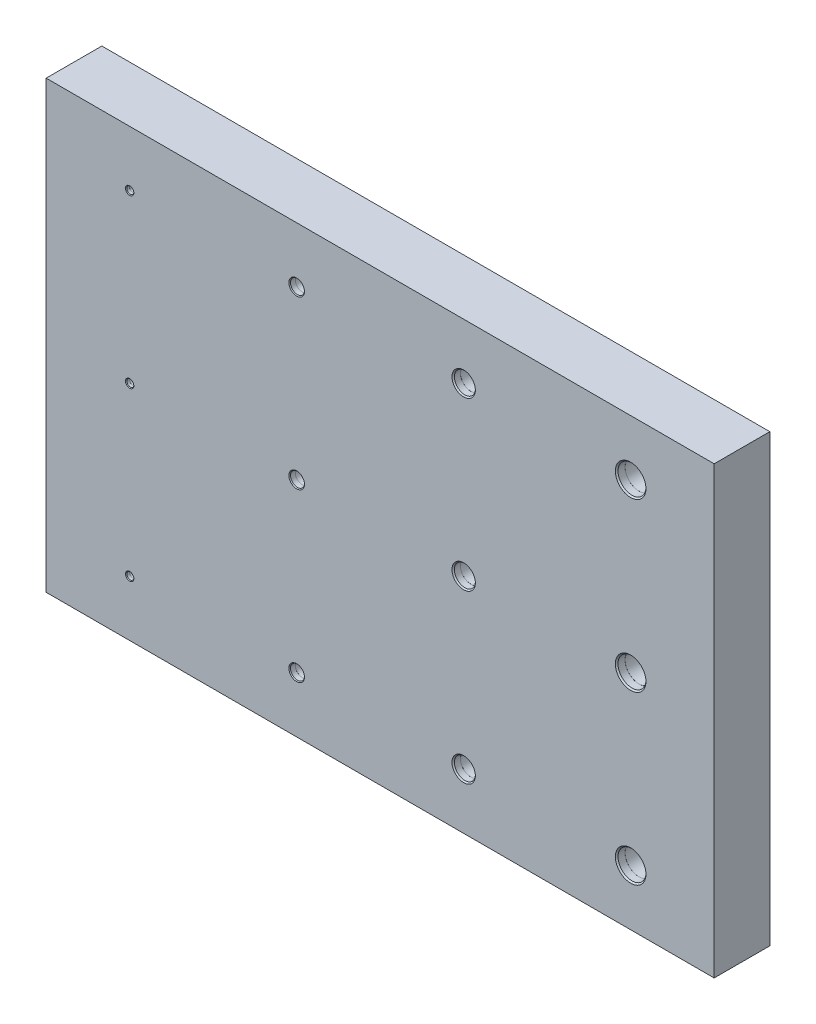
from build123d import *

# Parameters (mm, degrees)
SKETCH1_W                                     = 304.8
SKETCH1_H                                     = 203.2
BOSS_EXTRUDE1_DEPTH                           = 25.4
F_3_32_0_09375_DIAMETER_HOLE1_D               = 2.38125
CBORE_FOR_4_SOCKET_HEAD_CAP_SCREW1_AT_2_COUNT = 2
CBORE_FOR_4_SOCKET_HEAD_CAP_SCREW1_AT_2_PITCH = 76.2
CBORE_FOR_4_SOCKET_HEAD_CAP_SCREW1_AT_3_COUNT = 2
CBORE_FOR_4_SOCKET_HEAD_CAP_SCREW1_AT_3_PITCH = 152.4
CBORE_FOR_1_4_SOCKET_HEAD_CAP_SCREW1_AT_COUNT = 2
CBORE_FOR_1_4_SOCKET_HEAD_CAP_SCREW1_AT_PITCH = 76.2
CBORE_FOR_1_4_SOCKET_HEAD_CAP_SCREW1_2_COUNT  = 2
CBORE_FOR_1_4_SOCKET_HEAD_CAP_SCREW1_2_PITCH  = 152.4
CBORE_FOR_3_8_SOCKET_HEAD_CAP_SCREW1_AT_COUNT = 2
CBORE_FOR_3_8_SOCKET_HEAD_CAP_SCREW1_AT_PITCH = 76.2
CBORE_FOR_3_8_SOCKET_HEAD_CAP_SCREW1_2_COUNT  = 2
CBORE_FOR_3_8_SOCKET_HEAD_CAP_SCREW1_2_PITCH  = 152.4
CBORE_FOR_1_2_SOCKET_HEAD_CAP_SCREW1_AT_COUNT = 2
CBORE_FOR_1_2_SOCKET_HEAD_CAP_SCREW1_AT_PITCH = 76.2
CBORE_FOR_1_2_SOCKET_HEAD_CAP_SCREW1_2_COUNT  = 2
CBORE_FOR_1_2_SOCKET_HEAD_CAP_SCREW1_2_PITCH  = 152.4
F_3_16_0_1875_DIAMETER_HOLE1_D                = 4.7625
F_1_4_0_25_DIAMETER_HOLE1_D                   = 6.35
F_13_32_0_40625_DIAMETER_HOLE1_D              = 10.31875


with BuildPart() as part:
    # Sketch1 → Boss-Extrude1 (new body)
    with BuildSketch(Plane.XY):
        with Locations((152.4, 101.6)):
            Rectangle(SKETCH1_W, SKETCH1_H)
    extrude(amount=BOSS_EXTRUDE1_DEPTH)

    # 3/32 (0.09375) Diameter Hole1 (through all)
    with Locations(Plane.XY.offset(25.4)):
        with Locations((38.1, 177.8), (38.1, 101.6), (38.1, 25.4), (114.3, 177.8), (114.3, 101.6), (114.3, 25.4), (190.5, 177.8), (190.5, 101.6), (190.5, 25.4), (266.7, 177.8), (266.7, 101.6), (266.7, 25.4)):
            Hole(F_3_32_0_09375_DIAMETER_HOLE1_D / 2)

    # Sketch4 → CBORE for #4 Socket Head Cap Screw1 (revolve, cut)
    with BuildSketch(Plane(origin=(38.1, 177.8, 25.4), x_dir=(0, -1, 0), z_dir=(1, 0, 0))):
        Polygon((0, 0), (0, 7.303866233), (1.5875, 6.35), (1.5875, 1.524), (1.6002, 1.524), (1.6002, 0.3048), (1.905, 0), align=None)
    cbore_for_4_socket_head_cap_screw1 = revolve(axis=Axis((38.1, 177.8, 31.75), (0, 0, -1)), mode=Mode.SUBTRACT)

    # CBORE for #4 Socket Head Cap Screw1 at 2: CBORE for #4 Socket Head Cap Screw1 ×2
    with Locations(*[(0, -i * CBORE_FOR_4_SOCKET_HEAD_CAP_SCREW1_AT_2_PITCH, 0) for i in range(1, CBORE_FOR_4_SOCKET_HEAD_CAP_SCREW1_AT_2_COUNT)]):
        add(cbore_for_4_socket_head_cap_screw1, mode=Mode.SUBTRACT)

    # CBORE for #4 Socket Head Cap Screw1 at 3: CBORE for #4 Socket Head Cap Screw1 ×2
    with Locations(*[(0, -i * CBORE_FOR_4_SOCKET_HEAD_CAP_SCREW1_AT_3_PITCH, 0) for i in range(1, CBORE_FOR_4_SOCKET_HEAD_CAP_SCREW1_AT_3_COUNT)]):
        add(cbore_for_4_socket_head_cap_screw1, mode=Mode.SUBTRACT)

    # Sketch6 → CBORE for 1/4 Socket Head Cap Screw1 (revolve, cut)
    with BuildSketch(Plane(origin=(114.3, 177.8, 25.4), x_dir=(0, -1, 0), z_dir=(1, 0, 0))):
        Polygon((0, 0), (0, 11.432732465), (3.175, 9.525), (3.175, 2.54), (3.1877, 2.54), (3.1877, 0.3683), (3.556, 0), align=None)
    cbore_for_1_4_socket_head_cap_screw1 = revolve(axis=Axis((114.3, 177.8, 31.75), (0, 0, -1)), mode=Mode.SUBTRACT)

    # CBORE for 1/4 Socket Head Cap Screw1 at: CBORE for 1/4 Socket Head Cap Screw1 ×2
    with Locations(*[(0, -i * CBORE_FOR_1_4_SOCKET_HEAD_CAP_SCREW1_AT_PITCH, 0) for i in range(1, CBORE_FOR_1_4_SOCKET_HEAD_CAP_SCREW1_AT_COUNT)]):
        add(cbore_for_1_4_socket_head_cap_screw1, mode=Mode.SUBTRACT)

    # CBORE for 1_4 Socket Head Cap Screw1 2: CBORE for 1/4 Socket Head Cap Screw1 ×2
    with Locations(*[(0, -i * CBORE_FOR_1_4_SOCKET_HEAD_CAP_SCREW1_2_PITCH, 0) for i in range(1, CBORE_FOR_1_4_SOCKET_HEAD_CAP_SCREW1_2_COUNT)]):
        add(cbore_for_1_4_socket_head_cap_screw1, mode=Mode.SUBTRACT)

    # Sketch8 → CBORE for 3/8 Socket Head Cap Screw1 (revolve, cut)
    with BuildSketch(Plane(origin=(190.5, 177.8, 25.4), x_dir=(0, -1, 0), z_dir=(1, 0, 0))):
        Polygon((0, 0), (0, 18.101598698), (4.7625, 15.24), (4.7625, 3.302), (4.7879, 3.302), (4.7879, 0.5461), (5.334, 0), align=None)
    cbore_for_3_8_socket_head_cap_screw1 = revolve(axis=Axis((190.5, 177.8, 31.75), (0, 0, -1)), mode=Mode.SUBTRACT)

    # CBORE for 3/8 Socket Head Cap Screw1 at: CBORE for 3/8 Socket Head Cap Screw1 ×2
    with Locations(*[(0, -i * CBORE_FOR_3_8_SOCKET_HEAD_CAP_SCREW1_AT_PITCH, 0) for i in range(1, CBORE_FOR_3_8_SOCKET_HEAD_CAP_SCREW1_AT_COUNT)]):
        add(cbore_for_3_8_socket_head_cap_screw1, mode=Mode.SUBTRACT)

    # CBORE for 3_8 Socket Head Cap Screw1 2: CBORE for 3/8 Socket Head Cap Screw1 ×2
    with Locations(*[(0, -i * CBORE_FOR_3_8_SOCKET_HEAD_CAP_SCREW1_2_PITCH, 0) for i in range(1, CBORE_FOR_3_8_SOCKET_HEAD_CAP_SCREW1_2_COUNT)]):
        add(cbore_for_3_8_socket_head_cap_screw1, mode=Mode.SUBTRACT)

    # Sketch10 → CBORE for 1/2 Socket Head Cap Screw1 (revolve, cut)
    with BuildSketch(Plane(origin=(266.7, 177.8, 25.4), x_dir=(0, -1, 0), z_dir=(1, 0, 0))):
        Polygon((0, 0), (0, 22.865464931), (6.35, 19.05), (6.35, 3.81), (6.3754, 3.81), (6.3754, 0.6096), (6.985, 0), align=None)
    cbore_for_1_2_socket_head_cap_screw1 = revolve(axis=Axis((266.7, 177.8, 31.75), (0, 0, -1)), mode=Mode.SUBTRACT)

    # CBORE for 1/2 Socket Head Cap Screw1 at: CBORE for 1/2 Socket Head Cap Screw1 ×2
    with Locations(*[(0, -i * CBORE_FOR_1_2_SOCKET_HEAD_CAP_SCREW1_AT_PITCH, 0) for i in range(1, CBORE_FOR_1_2_SOCKET_HEAD_CAP_SCREW1_AT_COUNT)]):
        add(cbore_for_1_2_socket_head_cap_screw1, mode=Mode.SUBTRACT)

    # CBORE for 1_2 Socket Head Cap Screw1 2: CBORE for 1/2 Socket Head Cap Screw1 ×2
    with Locations(*[(0, -i * CBORE_FOR_1_2_SOCKET_HEAD_CAP_SCREW1_2_PITCH, 0) for i in range(1, CBORE_FOR_1_2_SOCKET_HEAD_CAP_SCREW1_2_COUNT)]):
        add(cbore_for_1_2_socket_head_cap_screw1, mode=Mode.SUBTRACT)

    # 3/16 (0.1875) Diameter Hole1 (through all)
    with Locations(Plane.XY.offset(25.4)):
        with Locations((114.3, 177.8), (114.3, 101.6), (114.3, 25.4)):
            Hole(F_3_16_0_1875_DIAMETER_HOLE1_D / 2)

    # 1/4 (0.25) Diameter Hole1 (through all)
    with Locations(Plane.XY.offset(25.4)):
        with Locations((190.5, 177.8), (190.5, 101.6), (190.5, 25.4)):
            Hole(F_1_4_0_25_DIAMETER_HOLE1_D / 2)

    # 13/32 (0.40625) Diameter Hole1 (through all)
    with Locations(Plane.XY.offset(25.4)):
        with Locations((266.7, 177.8), (266.7, 101.6), (266.7, 25.4)):
            Hole(F_13_32_0_40625_DIAMETER_HOLE1_D / 2)


solid = part.part
